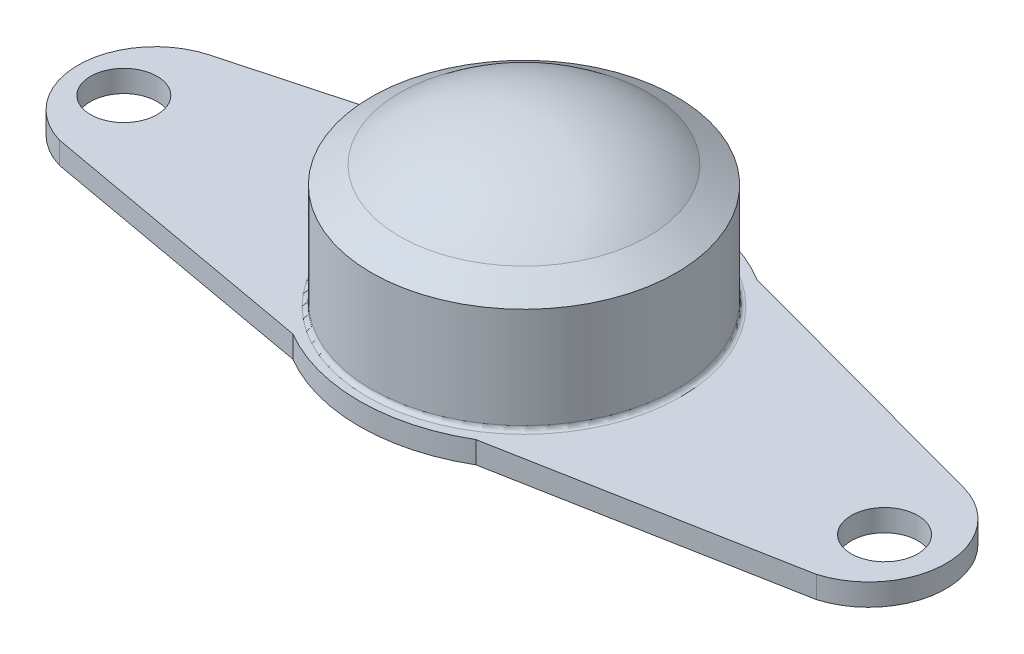
from build123d import *

# Parameters (mm, degrees)
BOSS_EXTRUDE2_DEPTH = 2.5
SKETCH3_R           = 17.40366437
BOSS_EXTRUDE3_DEPTH = 14
CHAMFER1_SIZE       = 2
CHAMFER1_SIZE2      = 3.200669058
DOME1_FACE_RADIUS   = 14.202995312
DOME1_HEIGHT        = 5.08
SKETCH4_R           = 3.794155
SKETCH4_R_2         = 3.79415255
CUT_EXTRUDE1_DEPTH  = 22.225
FILLET1_R           = 0.5


with BuildPart() as part:
    # Sketch2 → Boss-Extrude2 (new body)
    with BuildSketch(Plane(origin=(0, 0, 0), x_dir=(1, 0, 0), z_dir=(0, 1, 0))):
        with BuildLine():
            Line((-35.297990867, 36.146423133), (-67.605962497, 27.389534463))
            ThreePointArc((-67.605962497, 27.389534463), (-74.11985651, 18.96683835), (-67.783839922, 10.40953043))
            Line((-67.783839922, 10.40953043), (-35.297990867, 4.567846601))
            ThreePointArc((-35.297990867, 4.567846601), (-24.860460433, 1.727880743), (-14.422929998, 4.567846601))
            Line((-14.422929998, 4.567846601), (16.577836549, 10.352015281))
            Line((16.577836549, 10.352015281), (18.329761229, 10.678891968))
            ThreePointArc((18.329761229, 10.678891968), (24.665777818, 19.236199887), (18.151883804, 27.658896001))
            Line((18.151883804, 27.658896001), (-14.156087825, 36.415784671))
            ThreePointArc((-14.156087825, 36.415784671), (-24.766013326, 39.340130463), (-35.297990867, 36.146423133))
        make_face()
    extrude(amount=BOSS_EXTRUDE2_DEPTH)

    # Sketch3 → Boss-Extrude3 (add)
    with BuildSketch(Plane(origin=(0, 2.5, 0), x_dir=(1, 0, 0), z_dir=(0, 1, 0))):
        with Locations((-24.847892724, 20.495392169)):
            Circle(SKETCH3_R)
    extrude(amount=BOSS_EXTRUDE3_DEPTH)

    # Chamfer1
    chamfer1_edges = [part.edges().sort_by_distance(p)[0] for p in [
        (-42.251557093, 16.5, -20.495392169),
    ]]
    chamfer1_side = [part.faces().sort_by_distance(p)[0] for p in [
        (-42.251557093, 9.5, -20.495392169),
    ]]
    chamfer(chamfer1_edges, length=CHAMFER1_SIZE, length2=CHAMFER1_SIZE2, reference=chamfer1_side[0])

    # Dome1: a dome of height H over a round flat face of radius A is a cap of a sphere of radius (A * A + H * H) / (2 * H)
    dome1_r = (DOME1_FACE_RADIUS * DOME1_FACE_RADIUS + DOME1_HEIGHT * DOME1_HEIGHT) / (2 * DOME1_HEIGHT)
    dome1_base = Plane((-24.847892724, 16.5, -20.495392169), z_dir=(0, 1, 0))
    with Locations(dome1_base.offset(DOME1_HEIGHT - dome1_r)):
        dome1_ball = Sphere(dome1_r, mode=Mode.PRIVATE)
    add(split(dome1_ball, bisect_by=dome1_base, keep=Keep.TOP, mode=Mode.PRIVATE))

    # Sketch4 → Cut-Extrude1 (cut)
    with BuildSketch(Plane(origin=(0, 2.5, 0), x_dir=(1, 0, 0), z_dir=(0, 1, 0))):
        with Locations((18.303486059, 18.493262314)):
            Circle(SKETCH4_R)
        with Locations((-68.509987209, 18.493262314)):
            Circle(SKETCH4_R_2)
    extrude(amount=-CUT_EXTRUDE1_DEPTH, mode=Mode.SUBTRACT)

    # Fillet1
    fillet1_edges = [part.edges().sort_by_distance(p)[0] for p in [
        (-42.251557093, 2.5, -20.495392169),
    ]]
    fillet(fillet1_edges, radius=FILLET1_R)


solid = part.part
